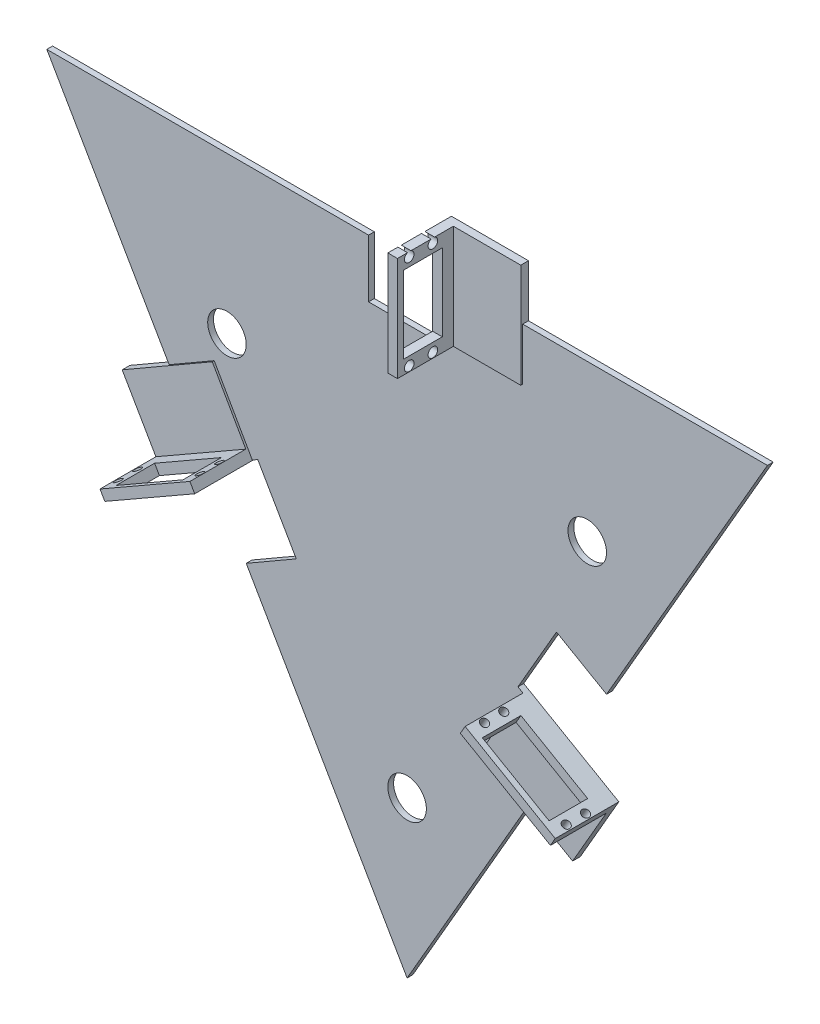
from build123d import *

# Parameters (mm, degrees)
BOSS_EXTRUDE1_DEPTH = 3
CUT_EXTRUDE2_DEPTH  = 10
CUT_EXTRUDE3_DEPTH  = 10
BOSS_EXTRUDE2_DEPTH = 4
SKETCH6_W           = 5
SKETCH6_H           = 54
BOSS_EXTRUDE3_DEPTH = 30
SKETCH8_R           = 2
SKETCH8_W           = 40
SKETCH8_H           = 20
CUT_EXTRUDE4_DEPTH  = 40
SKETCH9_R           = 2
SKETCH9_W           = 40
SKETCH9_H           = 20
CUT_EXTRUDE5_DEPTH  = 40
SKETCH13_R          = 2.5
SKETCH13_W          = 20
SKETCH13_H          = 40
CUT_EXTRUDE6_DEPTH  = 40
SKETCH14_R          = 10
CUT_EXTRUDE7_DEPTH  = 10


with BuildPart() as part:
    # Sketch2 → Boss-Extrude1 (new body)
    with BuildSketch(Plane.XY):
        Polygon((-187, 161.946750508), (187, 161.946750508), (0, -161.946750508), align=None)
    extrude(amount=BOSS_EXTRUDE1_DEPTH)

    # Sketch3 → Cut-Extrude2 (cut)
    with BuildSketch(Plane.XY):
        Polygon((-83.5, -17.320508076), (-57.519237886, -2.320508076), (-77.519237886, 32.320508076), (-103.5, 17.320508076), align=None)
        Polygon((57.519237886, -2.320508076), (83.5, -17.320508076), (103.5, 17.320508076), (77.519237886, 32.320508076), align=None)
    extrude(amount=CUT_EXTRUDE2_DEPTH, mode=Mode.SUBTRACT)

    # Sketch4 → Cut-Extrude3 (cut)
    with BuildSketch(Plane.XY):
        Polygon((0, 131.946750508), (20, 131.946750508), (20, 161.946750508), (0, 161.946750508), (-20, 161.946750508), (-20, 131.946750508), align=None)
    extrude(amount=CUT_EXTRUDE3_DEPTH, mode=Mode.SUBTRACT)

    # Sketch5 → Boss-Extrude2 (add)
    with BuildSketch(Plane.XY):
        Polygon((-103.5, 17.320508076), (-80.25426683, 30.543976819), (-100.117314098, 65.461524227), (-123.5, 51.961524227), (-146.882685902, 38.461524227), (-126.882685902, 3.820508076), align=None)
        Polygon((20, 161.946750508), (20, 134.946750508), (60, 134.946750508), (60, 161.946750508), (60, 188.946750508), (20, 188.946750508), align=None)
        Polygon((83.5, -17.320508076), (60.117314098, -3.820508076), (40.117314098, -38.461524227), (63.5, -51.961524227), (86.882685902, -65.461524227), (106.882685902, -30.820508076), align=None)
    extrude(amount=BOSS_EXTRUDE2_DEPTH)

    # Sketch6 → Boss-Extrude3 (add)
    with BuildSketch(Plane.XY.offset(3)):
        Polygon((-126.882685902, 3.820508076), (-80.25426683, 30.543976819), (-82.726527648, 34.89000103), (-129.382685902, 8.150635095), align=None)
        Polygon((60.117314098, -3.820508076), (106.882685902, -30.820508076), (104.382685902, -35.150635095), (57.617314098, -8.150635095), align=None)
        with Locations((22.5, 161.946750508)):
            Rectangle(SKETCH6_W, SKETCH6_H)
    extrude(amount=BOSS_EXTRUDE3_DEPTH)

    # Sketch8 → Cut-Extrude4 (cut)
    with BuildSketch(Plane(origin=(-33.019892419, 57.614727947, 0), x_dir=(0.867611975, 0.497241853, 0), z_dir=(0.497241853, -0.867611975, 0))):
        with Locations((-56.728666482, 15.70430261)):
            Circle(SKETCH8_R)
        with Locations((-56.728666482, 25.70430261)):
            Circle(SKETCH8_R)
        with Locations((-105.728666482, 25.70430261)):
            Circle(SKETCH8_R)
        with Locations((-105.728666482, 15.70430261)):
            Circle(SKETCH8_R)
        with Locations((-81.228666482, 20.70430261)):
            Rectangle(SKETCH8_W, SKETCH8_H)
    extrude(amount=-CUT_EXTRUDE4_DEPTH, mode=Mode.SUBTRACT)

    # Sketch9 → Cut-Extrude5 (cut)
    with BuildSketch(Plane(origin=(10.875, 18.836052532, 0), x_dir=(0.866025404, -0.5, 0), z_dir=(-0.5, -0.866025404, 0))):
        with Locations((105.471828454, 15.12829127)):
            Circle(SKETCH9_R)
        with Locations((105.471828454, 25.12829127)):
            Circle(SKETCH9_R)
        with Locations((56.471828454, 25.12829127)):
            Circle(SKETCH9_R)
        with Locations((56.471828454, 15.12829127)):
            Circle(SKETCH9_R)
        with Locations((80.971828454, 20.12829127)):
            Rectangle(SKETCH9_W, SKETCH9_H)
    extrude(amount=-CUT_EXTRUDE5_DEPTH, mode=Mode.SUBTRACT)

    # Sketch13 → Cut-Extrude6 (cut)
    with BuildSketch(Plane(origin=(25, 0, 0), x_dir=(0, 0, -1), z_dir=(1, 0, 0))):
        with Locations((-26.890806587, 137.608868151)):
            Circle(SKETCH13_R)
        with Locations((-14.632269725, 137.608868151)):
            Circle(SKETCH13_R)
        with Locations((-26.890806587, 186.608868151)):
            Circle(SKETCH13_R)
        with Locations((-14.632269725, 186.608868151)):
            Circle(SKETCH13_R)
        with Locations((-19.755862456, 162.108868151)):
            Rectangle(SKETCH13_W, SKETCH13_H)
    extrude(amount=-CUT_EXTRUDE6_DEPTH, mode=Mode.SUBTRACT)

    # Sketch14 → Cut-Extrude7 (cut)
    with BuildSketch(Plane(origin=(0, 0, 0), x_dir=(-1, 0, 0), z_dir=(0, 0, -1))):
        with Locations((0, -80.973375254)):
            Circle(SKETCH14_R)
        with Locations((93.5, 80.973375254)):
            Circle(SKETCH14_R)
        with Locations((-93.5, 80.973375254)):
            Circle(SKETCH14_R)
    extrude(amount=-CUT_EXTRUDE7_DEPTH, mode=Mode.SUBTRACT)


solid = part.part
